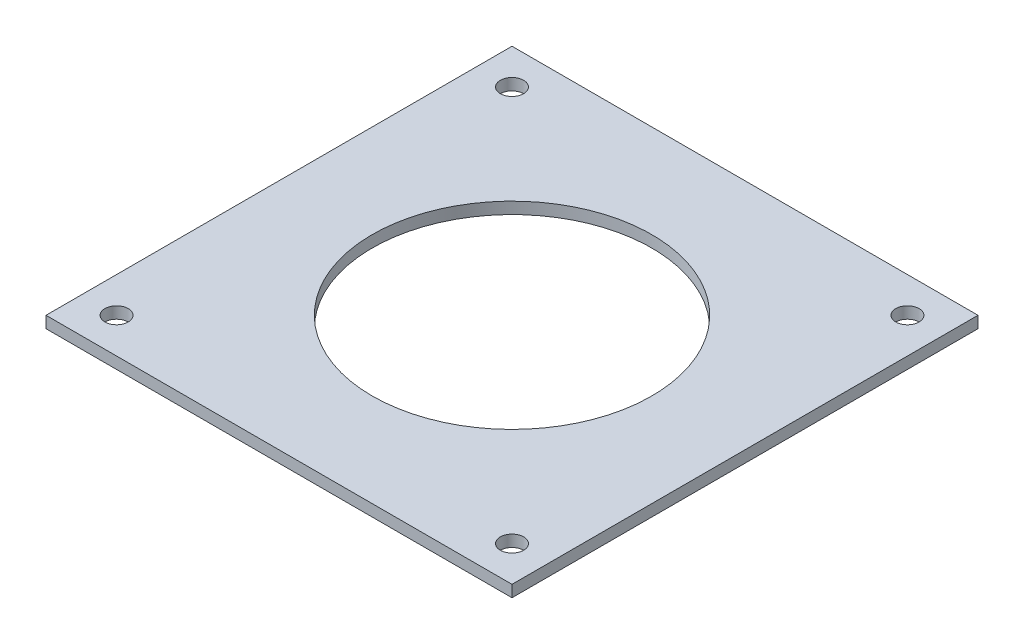
from build123d import *

# Parameters (mm, degrees)
SKETCH1_W           = 127
SKETCH1_H           = 127
SKETCH1_R           = 38.1
SKETCH1_R_2         = 3.175
BOSS_EXTRUDE1_DEPTH = 3.175


with BuildPart() as part:
    # Sketch1 → Boss-Extrude1 (new body)
    with BuildSketch(Plane(origin=(0, 0, 0), x_dir=(1, 0, 0), z_dir=(0, 1, 0))):
        Rectangle(SKETCH1_W, SKETCH1_H)
        Circle(SKETCH1_R, mode=Mode.SUBTRACT)
        with Locations((-53.881536726, 53.881536726)):
            Circle(SKETCH1_R_2, mode=Mode.SUBTRACT)
        with Locations((53.881536726, 53.881536726)):
            Circle(SKETCH1_R_2, mode=Mode.SUBTRACT)
        with Locations((53.881536726, -53.881536726)):
            Circle(SKETCH1_R_2, mode=Mode.SUBTRACT)
        with Locations((-53.881536726, -53.881536726)):
            Circle(SKETCH1_R_2, mode=Mode.SUBTRACT)
    extrude(amount=BOSS_EXTRUDE1_DEPTH)


solid = part.part
